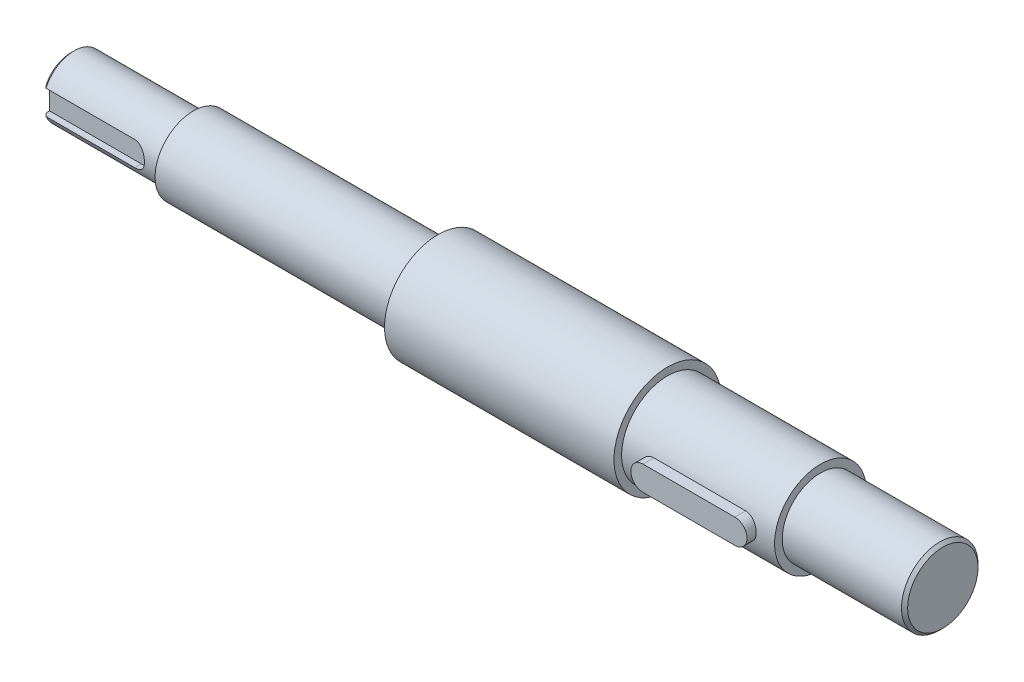
from build123d import *

# Parameters (mm, degrees)
SKETCH2_W           = 30
SKETCH2_H           = 8
CUT_EXTRUDE2_DEPTH  = 3
SKETCH3_W           = 42.75
SKETCH3_H           = 8
CUT_EXTRUDE3_DEPTH  = 3
CHAMFER1_SIZE       = 1
BOSS_EXTRUDE1_DEPTH = 6


with BuildPart() as part:
    # Sketch1 → Revolve1 (revolve)
    with BuildSketch(Plane(origin=(0, 0, 0), x_dir=(1, 0, 0), z_dir=(0, 1, 0))):
        Polygon((0, 0), (0, -10), (40, -10), (40, -12.5), (120, -12.5), (120, -17.5), (195, -17.5), (195, -15), (245, -15), (245, -12.5), (285, -12.5), (285, 0), align=None)
    revolve(axis=Axis((285, 0, 0), (-1, 0, 0)))

    # Sketch2 → Cut-Extrude2 (cut)
    with BuildSketch(Plane(origin=(0, 0, 15), x_dir=(-1, 0, 0), z_dir=(0, 0, -1))):
        with Locations((-220, 0)):
            Rectangle(SKETCH2_W, SKETCH2_H)
        with BuildLine():
            Line((-235, -4), (-235, 4))
            ThreePointArc((-235, 4), (-239, 0), (-235, -4))
        make_face()
        with BuildLine():
            Line((-205, -4), (-205, 4))
            ThreePointArc((-205, 4), (-201, 0), (-205, -4))
        make_face()
    extrude(amount=CUT_EXTRUDE2_DEPTH, mode=Mode.SUBTRACT)

    # Sketch3 → Cut-Extrude3 (cut)
    with BuildSketch(Plane.XY.offset(10)):
        with Locations((8.625, 0)):
            Rectangle(SKETCH3_W, SKETCH3_H)
        with BuildLine():
            Line((30, -4), (30, 4))
            ThreePointArc((30, 4), (34, 0), (30, -4))
        make_face()
    extrude(amount=-CUT_EXTRUDE3_DEPTH, mode=Mode.SUBTRACT)

    # Chamfer1
    chamfer1_edges = [part.edges().sort_by_distance(p)[0] for p in [
        (0, 0, -10),
        (285, 0, -12.5),
    ]]
    chamfer(chamfer1_edges, length=CHAMFER1_SIZE)

    # Sketch9 → Boss-Extrude1 (add)
    with BuildSketch(Plane.XY.offset(12)):
        with BuildLine():
            Line((235, 4), (205, 4))
            ThreePointArc((205, 4), (201, 0), (205, -4))
            Line((205, -4), (235, -4))
            ThreePointArc((235, -4), (239, 0), (235, 4))
        make_face()
    extrude(amount=BOSS_EXTRUDE1_DEPTH)


solid = part.part
